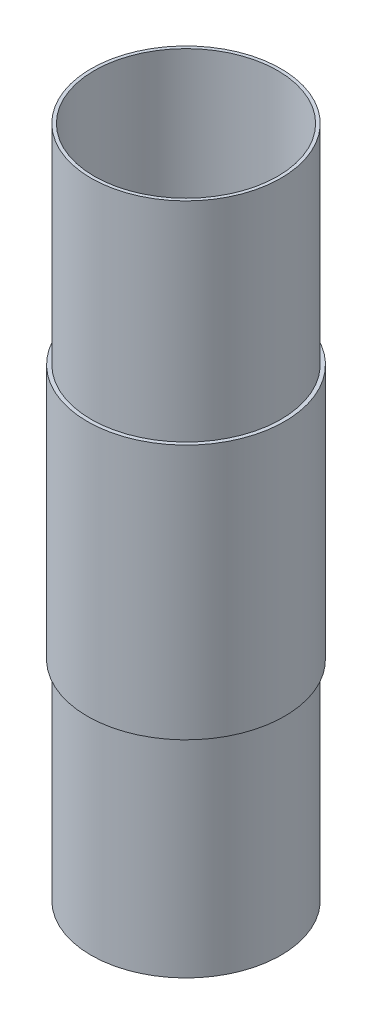
from build123d import *

# Parameters (mm, degrees)
SKETCH1_R           = 40.9
SKETCH1_R_2         = 39.5
BOSS_EXTRUDE1_DEPTH = 145
SKETCH1_3_R         = 42.5
SKETCH1_3_R_2       = 40.9
BOSS_EXTRUDE2_DEPTH = 55


with BuildPart() as part:
    # Sketch1 → Boss-Extrude1 (new, symmetric)
    with BuildSketch(Plane(origin=(0, 0, 0), x_dir=(1, 0, 0), z_dir=(0, 1, 0))):
        Circle(SKETCH1_R)
        Circle(SKETCH1_R_2, mode=Mode.SUBTRACT)
    extrude(amount=BOSS_EXTRUDE1_DEPTH, both=True)

    # Sketch1_3 → Boss-Extrude2 (add, symmetric)
    with BuildSketch(Plane(origin=(0, 0, 0), x_dir=(1, 0, 0), z_dir=(0, 1, 0))):
        Circle(SKETCH1_3_R)
        Circle(SKETCH1_3_R_2, mode=Mode.SUBTRACT)
    extrude(amount=BOSS_EXTRUDE2_DEPTH, both=True)


solid = part.part
